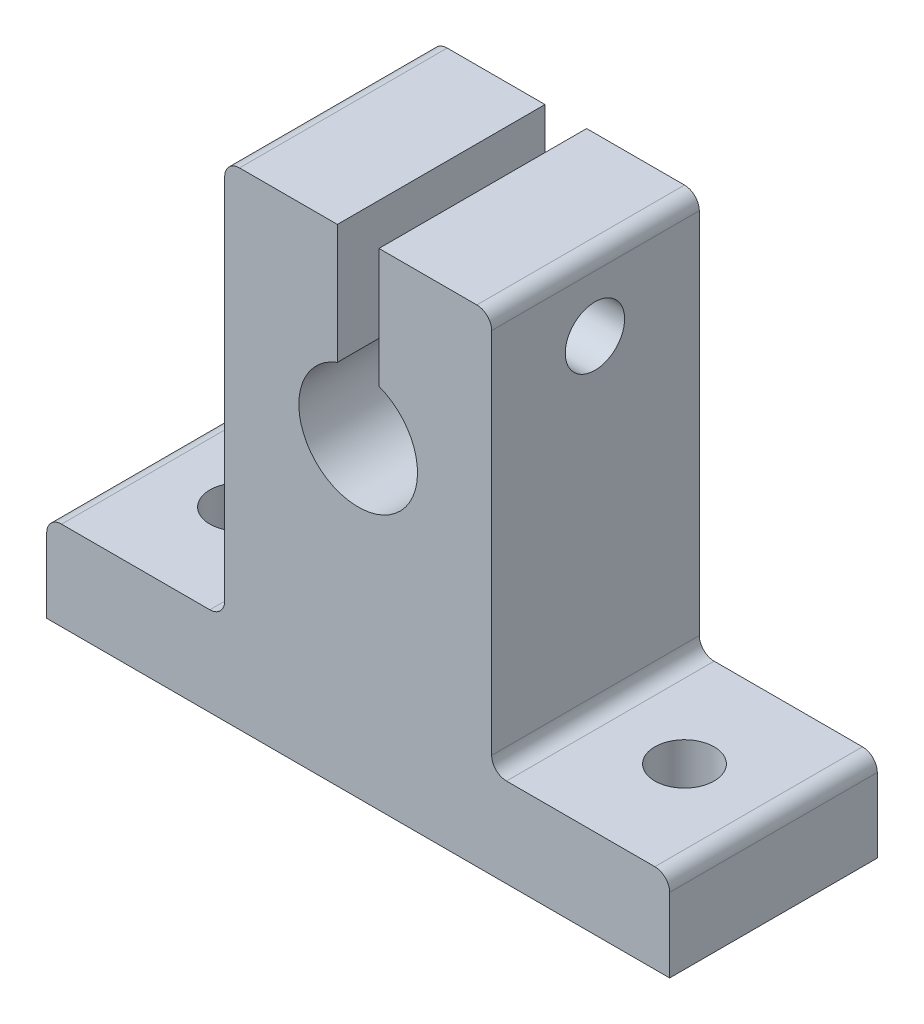
from build123d import *

# Parameters (mm, degrees)
Y_KSEKLIK_EKSTR_ZYON1_DEPTH = 14
IZIM2_R                     = 2
KES_EKSTR_ZYON1_DEPTH       = 14
IZIM3_R                     = 2
KES_EKSTR_ZYON2_DEPTH       = 50


with BuildPart() as part:
    # Çizim1 → Yükseklik-Ekstrüzyon1 (new body)
    with BuildSketch(Plane.XY):
        with BuildLine():
            Line((-58.370675481, 0), (-16.370675481, 0))
            Line((-16.370675481, 0), (-16.370675481, 5))
            ThreePointArc((-16.370675481, 5), (-16.663568699, 5.707106781), (-17.370675481, 6))
            Line((-17.370675481, 6), (-27.370675481, 6))
            ThreePointArc((-27.370675481, 6), (-28.077782262, 6.292893219), (-28.370675481, 7))
            Line((-28.370675481, 7), (-28.370675481, 31.8))
            ThreePointArc((-28.370675481, 31.8), (-28.663568699, 32.507106781), (-29.370675481, 32.8))
            Line((-29.370675481, 32.8), (-35.968113831, 32.8))
            Line((-35.968113831, 32.8), (-35.968113831, 24.746040686))
            ThreePointArc((-35.968113831, 24.746040686), (-37.370675481, 17), (-38.77323713, 24.746040686))
            Line((-38.77323713, 24.746040686), (-38.77323713, 32.8))
            Line((-38.77323713, 32.8), (-45.370675481, 32.8))
            ThreePointArc((-45.370675481, 32.8), (-46.077782262, 32.507106781), (-46.370675481, 31.8))
            Line((-46.370675481, 31.8), (-46.370675481, 7))
            ThreePointArc((-46.370675481, 7), (-46.663568699, 6.292893219), (-47.370675481, 6))
            Line((-47.370675481, 6), (-57.370675481, 6))
            ThreePointArc((-57.370675481, 6), (-58.077782262, 5.707106781), (-58.370675481, 5))
            Line((-58.370675481, 5), (-58.370675481, 0))
        make_face()
    extrude(amount=Y_KSEKLIK_EKSTR_ZYON1_DEPTH)

    # Çizim2 → Kes-Ekstrüzyon1 (cut)
    with BuildSketch(Plane(origin=(0, 6, 0), x_dir=(1, 0, 0), z_dir=(0, 1, 0))):
        with Locations((-22.370675481, -7)):
            Circle(IZIM2_R)
        with Locations((-52.370675481, -7)):
            Circle(IZIM2_R)
    extrude(amount=-KES_EKSTR_ZYON1_DEPTH, mode=Mode.SUBTRACT)

    # Çizim3 → Kes-Ekstrüzyon2 (cut)
    with BuildSketch(Plane(origin=(-28.370675481, 0, 0), x_dir=(0, 0, -1), z_dir=(1, 0, 0))):
        with Locations((-7.037491544, 28)):
            Circle(IZIM3_R)
    extrude(amount=-KES_EKSTR_ZYON2_DEPTH, mode=Mode.SUBTRACT)


solid = part.part
